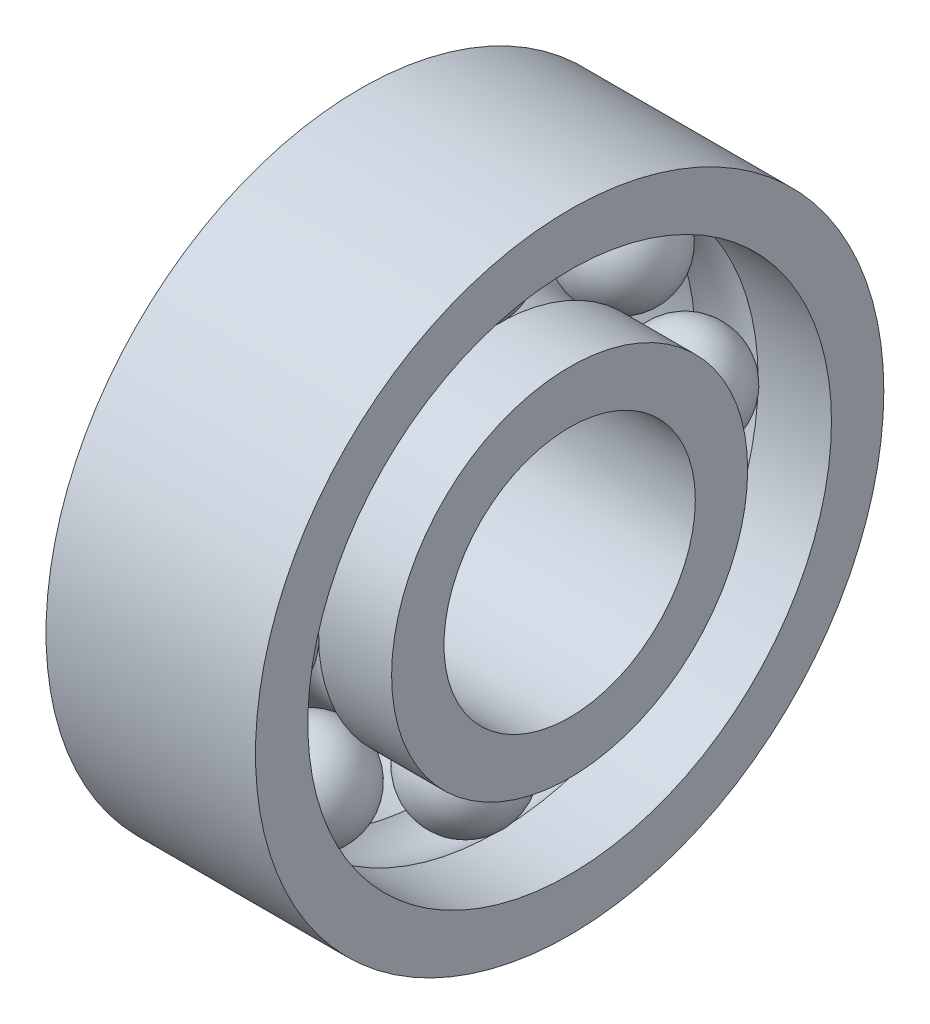
from build123d import *

# Parameters (mm, degrees)
CIRPATTERN2_COUNT = 8


with BuildPart() as part:
    # Sketch1 → Revolve1 (revolve)
    with BuildSketch(Plane.XY):
        with BuildLine():
            Line((5, 7.5), (0, 7.5))
            Line((0, 7.5), (0, 6.25))
            Line((0, 6.25), (1.75, 6.25))
            ThreePointArc((1.75, 6.25), (2.5, 6.5), (3.25, 6.25))
            Line((3.25, 6.25), (5, 6.25))
            Line((5, 6.25), (5, 7.5))
        make_face()
        with BuildLine():
            ThreePointArc((3.25, 4.25), (2.5, 4), (1.75, 4.25))
            Line((1.75, 4.25), (0, 4.25))
            Line((0, 4.25), (0, 3))
            Line((0, 3), (5, 3))
            Line((5, 3), (5, 4.25))
            Line((5, 4.25), (3.25, 4.25))
        make_face()
    revolve(axis=Axis((88.99, 0, 0), (-1, 0, 0)))


with BuildPart() as body_2:
    # Sketch1_3 → Revolve2 (revolve)
    with BuildSketch(Plane.XY):
        with BuildLine():
            Line((2.5, 4), (2.5, 6.5))
            ThreePointArc((2.5, 6.5), (2.104715292, 6.435854123), (1.75, 6.25))
            ThreePointArc((1.75, 6.25), (1.25, 5.25), (1.75, 4.25))
            ThreePointArc((1.75, 4.25), (2.104715292, 4.064145877), (2.5, 4))
        make_face()
    revolve(axis=Axis((2.5, 7.5, 0), (0, -1, 0)))


with BuildPart() as cirpattern2_1:
    # CirPattern2: pattern copy
    add(body_2.part.rotate(Axis((88.99, 0, 0), (-1, 0, 0)), 1 * 360 / CIRPATTERN2_COUNT))


with BuildPart() as cirpattern2_2:
    # CirPattern2: pattern copy
    add(body_2.part.rotate(Axis((88.99, 0, 0), (-1, 0, 0)), 2 * 360 / CIRPATTERN2_COUNT))


with BuildPart() as cirpattern2_3:
    # CirPattern2: pattern copy
    add(body_2.part.rotate(Axis((88.99, 0, 0), (-1, 0, 0)), 3 * 360 / CIRPATTERN2_COUNT))


with BuildPart() as cirpattern2_4:
    # CirPattern2: pattern copy
    add(body_2.part.rotate(Axis((88.99, 0, 0), (-1, 0, 0)), 4 * 360 / CIRPATTERN2_COUNT))


with BuildPart() as cirpattern2_5:
    # CirPattern2: pattern copy
    add(body_2.part.rotate(Axis((88.99, 0, 0), (-1, 0, 0)), 5 * 360 / CIRPATTERN2_COUNT))


with BuildPart() as cirpattern2_6:
    # CirPattern2: pattern copy
    add(body_2.part.rotate(Axis((88.99, 0, 0), (-1, 0, 0)), 6 * 360 / CIRPATTERN2_COUNT))


with BuildPart() as cirpattern2_7:
    # CirPattern2: pattern copy
    add(body_2.part.rotate(Axis((88.99, 0, 0), (-1, 0, 0)), 7 * 360 / CIRPATTERN2_COUNT))


solid = Compound([part.part, body_2.part, cirpattern2_1.part, cirpattern2_2.part, cirpattern2_3.part, cirpattern2_4.part, cirpattern2_5.part, cirpattern2_6.part, cirpattern2_7.part])
